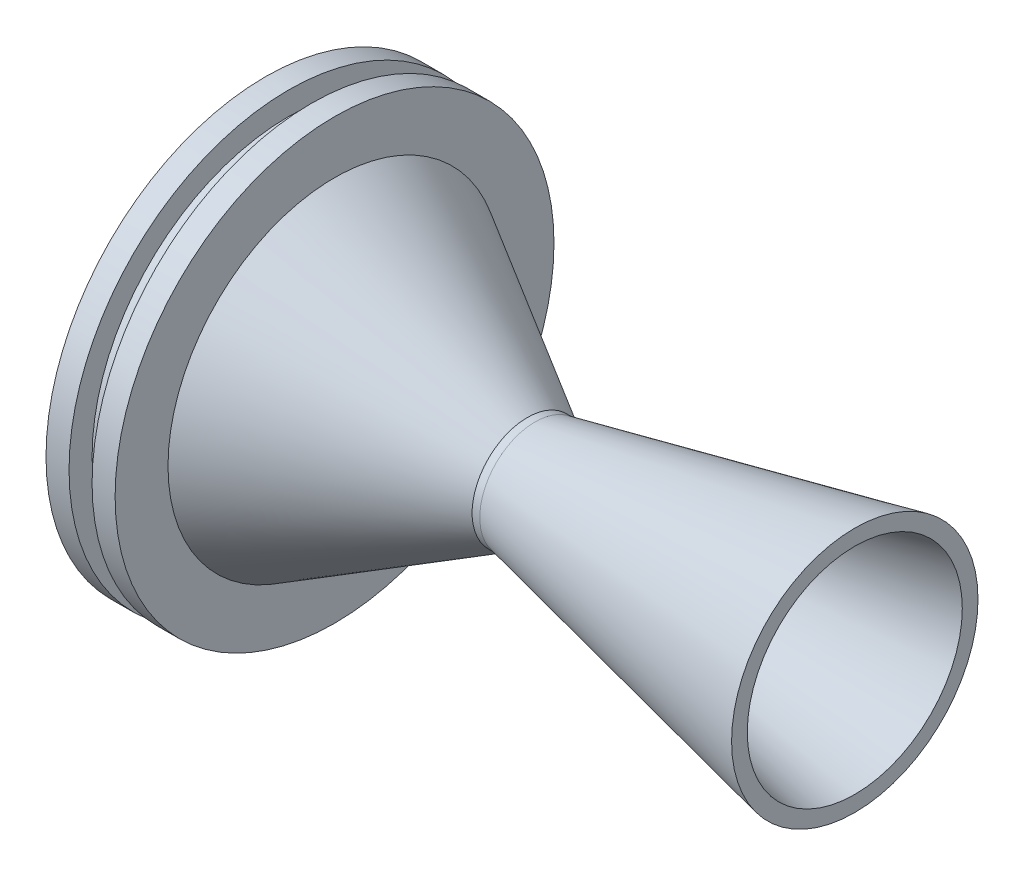
from build123d import *


with BuildPart() as part:
    # Esboço1 → Revolução1 (revolve)
    with BuildSketch(Plane.XY):
        Polygon((0, 28.575), (0, 24.575), (33.904894558, 5), (34.404894558, 5), (76.746565543, 14), (76.746565543, 16.04468119), (35.105477209, 7.193594629), (34.105477209, 7.193594629), (9, 21.688248654), (9, 28.575), (6, 28.575), (6, 25.575), (3, 25.575), (3, 28.575), align=None)
    revolve(axis=Axis((0, 0, 0), (-1, 0, 0)))


solid = part.part
